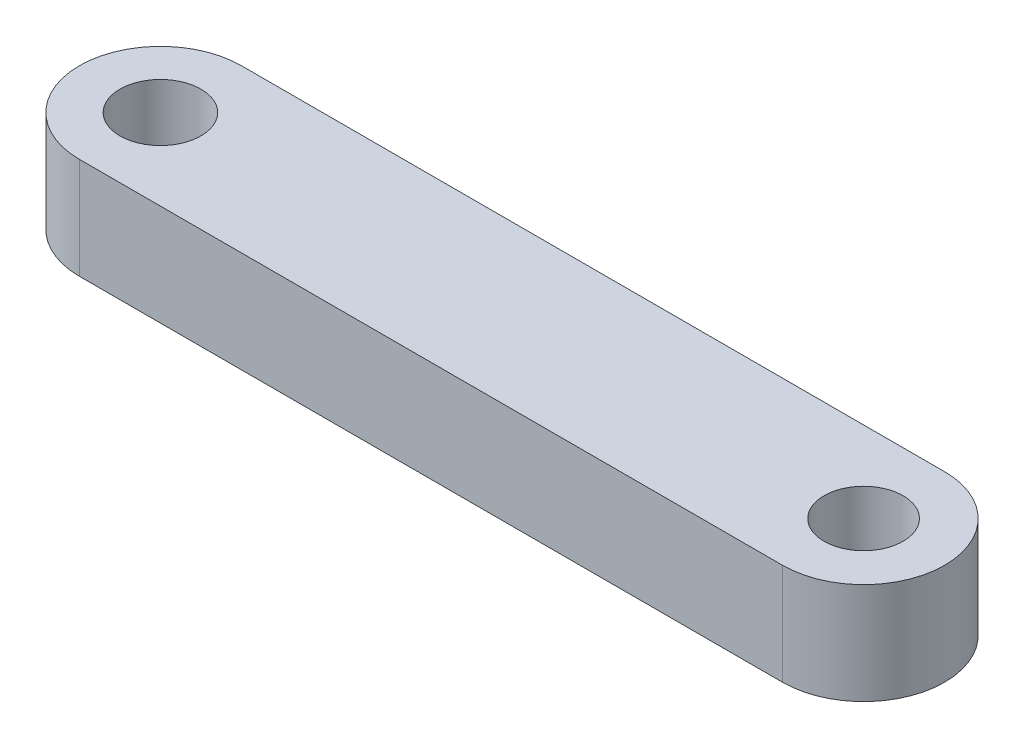
from build123d import *

# Parameters (mm, degrees)
SKETCH_1_R      = 2
SKETCH_1_R_2    = 1.95
EXTRUDE_1_DEPTH = 5


with BuildPart() as part:
    # 草图1 → 凸台-拉伸1 (new body)
    with BuildSketch(Plane(origin=(0, 0, 0), x_dir=(1, 0, 0), z_dir=(0, 1, 0))):
        with BuildLine():
            Line((0, 4), (34.702, 4))
            ThreePointArc((34.702, 4), (38.702, 0), (34.702, -4))
            Line((34.702, -4), (0, -4))
            ThreePointArc((0, -4), (-4, 0), (0, 4))
        make_face()
        Circle(SKETCH_1_R, mode=Mode.SUBTRACT)
        with Locations((34.702, 0)):
            Circle(SKETCH_1_R_2, mode=Mode.SUBTRACT)
    extrude(amount=EXTRUDE_1_DEPTH)


solid = part.part
